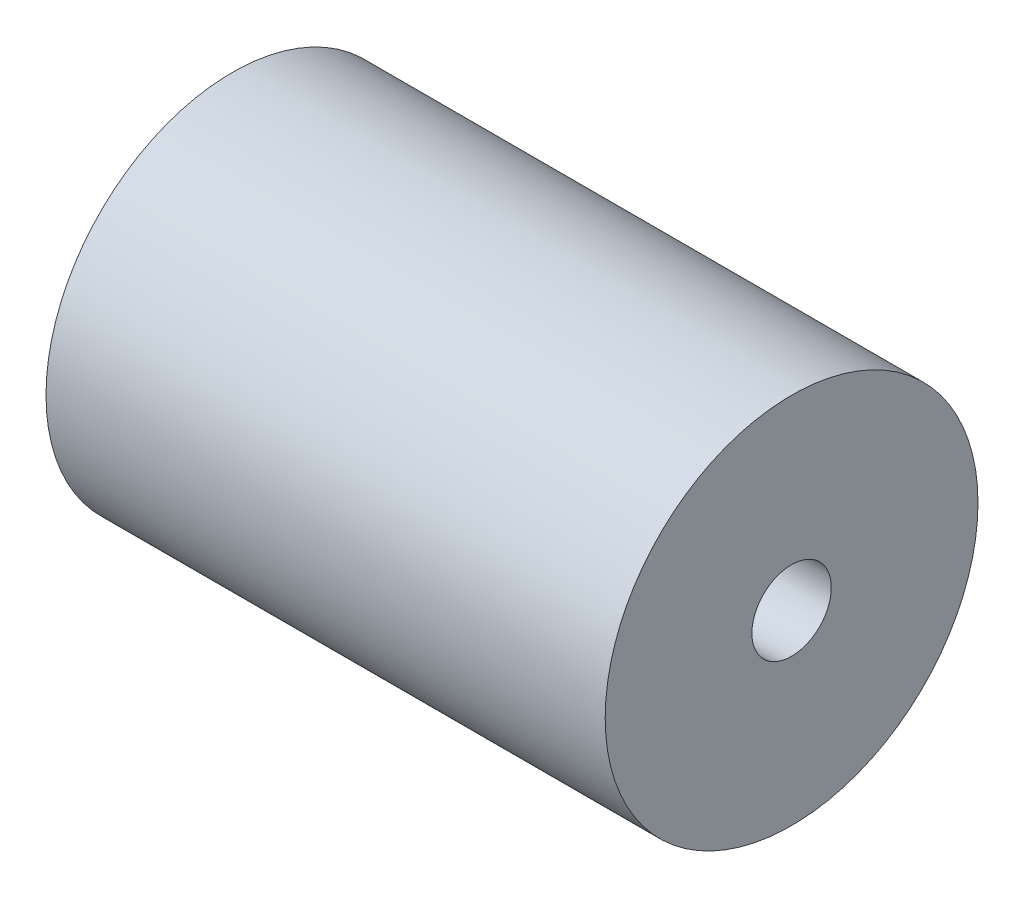
from build123d import *

# Parameters (mm, degrees)
SKETCH1_R             = 6.35
BOSS_EXTRUDE1_DEPTH   = 19.05
F_6_32_TAPPED_HOLE1_D = 2.7051


with BuildPart() as part:
    # Sketch1 → Boss-Extrude1 (new body)
    with BuildSketch(Plane(origin=(0, 0, 0), x_dir=(0, 0, -1), z_dir=(1, 0, 0))):
        Circle(SKETCH1_R)
    extrude(amount=BOSS_EXTRUDE1_DEPTH)

    # #6-32 Tapped Hole1 (through all)
    with Locations(Plane.ZY):
        with Locations((0, 0)):
            Hole(F_6_32_TAPPED_HOLE1_D / 2)


solid = part.part
